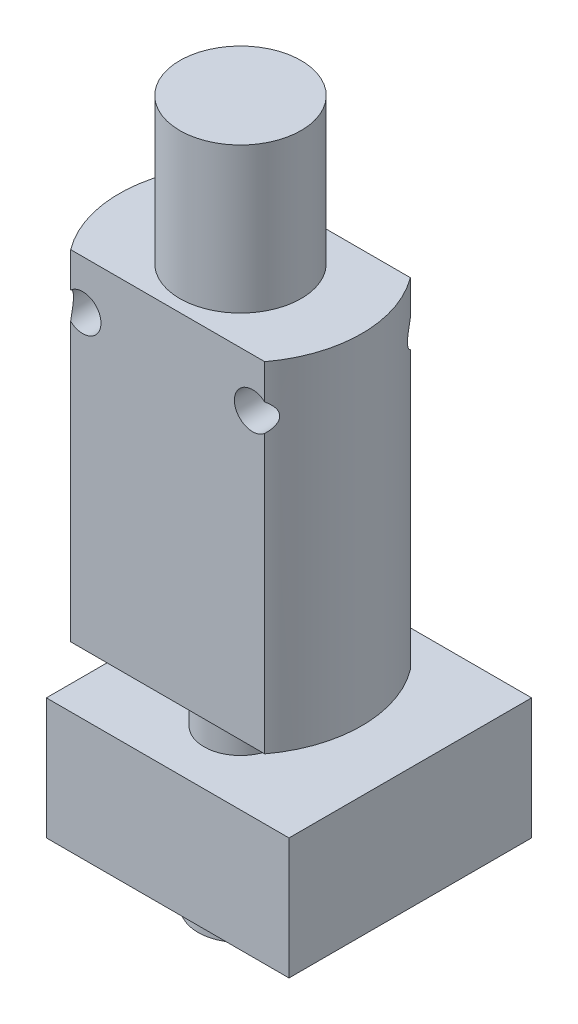
from build123d import *

# Parameters (mm, degrees)
ESBO_O1_W                = 20
ESBO_O1_H                = 28
ESBO_O1_R                = 1.5
RESSALTO_EXTRUS_O1_DEPTH = 6
ESBO_O2_W                = 5
ESBO_O2_H                = 12
RESSALTO_EXTRUS_O2_START = -29
ESBO_O3_W                = 20
ESBO_O3_H                = 20
RESSALTO_EXTRUS_O2_DEPTH = 10
CORTE_EXTRUS_O1_DEPTH    = 28


with BuildPart() as part:
    # Esboço1 → Ressalto-extrusão1 (new body, symmetric)
    with BuildSketch(Plane.XY):
        Rectangle(ESBO_O1_W, ESBO_O1_H)
        with Locations((-7, 10)):
            Circle(ESBO_O1_R, mode=Mode.SUBTRACT)
        with Locations((7, 10)):
            Circle(ESBO_O1_R, mode=Mode.SUBTRACT)
    extrude(amount=RESSALTO_EXTRUS_O1_DEPTH, both=True)

    # Esboço2 → Revolução1 (revolve)
    with BuildSketch(Plane.XY):
        Polygon((3, -29), (3, -19), (3, -14), (0, -14), (0, -34), (0.75, -34), (3.5, -32), (3.5, -29), align=None)
        with Locations((2.5, 20)):
            Rectangle(ESBO_O2_W, ESBO_O2_H)
    revolve(axis=Axis((0, 0, 0), (0, -1, 0)))

    # Esboço3 → Ressalto-extrusão2 (add)
    with BuildSketch(Plane(origin=(0, 0, 0), x_dir=(1, 0, 0), z_dir=(0, 1, 0)).offset(RESSALTO_EXTRUS_O2_START)):
        with Locations((0, 4)):
            Rectangle(ESBO_O3_W, ESBO_O3_H)
    extrude(amount=RESSALTO_EXTRUS_O2_DEPTH)

    # Esboço4 → Corte-extrusão1 (cut)
    with BuildSketch(Plane(origin=(0, 14, 0), x_dir=(1, 0, 0), z_dir=(0, 1, 0))):
        with BuildLine():
            ThreePointArc((-10, 0), (-9.486832981, 3.16227766), (-8, 6))
            Line((-8, 6), (-10, 6))
            Line((-10, 6), (-10, 0))
        make_face()
        with BuildLine():
            ThreePointArc((-8, -6), (-9.486832981, -3.16227766), (-10, 0))
            Line((-10, 0), (-10, -6))
            Line((-10, -6), (-8, -6))
        make_face()
        with BuildLine():
            Line((10, -6), (10, 0))
            ThreePointArc((10, 0), (9.486832981, -3.16227766), (8, -6))
            Line((8, -6), (10, -6))
        make_face()
        with BuildLine():
            Line((10, 6), (8, 6))
            ThreePointArc((8, 6), (9.486832981, 3.16227766), (10, 0))
            Line((10, 0), (10, 6))
        make_face()
    extrude(amount=-CORTE_EXTRUS_O1_DEPTH, mode=Mode.SUBTRACT)


solid = part.part
